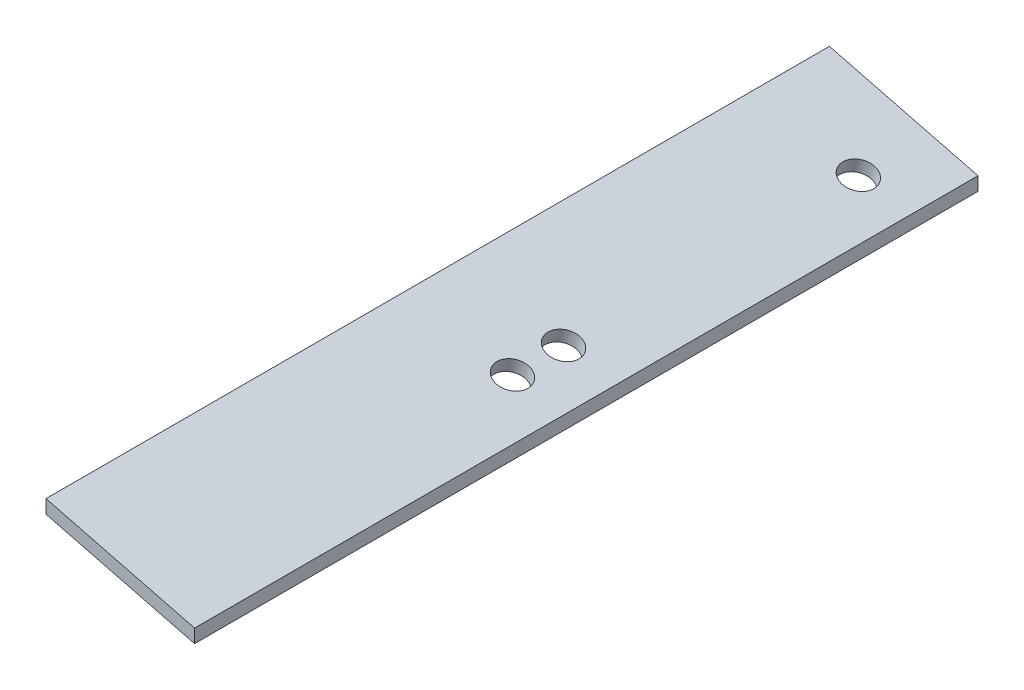
from build123d import *

# Parameters (mm, degrees)
BOSS_EXTRU_1_DEPTH      = 580
ESQUISSE2_R             = 11.8
ENL_V_MAT_EXTRU_1_DEPTH = 10


with BuildPart() as part:
    # Esquisse1 → Boss.-Extru.1 (new body)
    with BuildSketch(Plane.XY):
        Polygon((120, 155), (10, 183), (10, 173), (120, 145), align=None)
    extrude(amount=-BOSS_EXTRU_1_DEPTH)

    # Esquisse2 → Enlèv. mat.-Extru.1 (cut)
    with BuildSketch(Plane(origin=(44.355790127, 174.254889786, 0), x_dir=(0.969097174, -0.246679281, 0), z_dir=(0.246679281, 0.969097174, 0))):
        with Locations((41.344408766, 308.745926628)):
            Circle(ESQUISSE2_R)
        with Locations((41.344408766, 270.946985721)):
            Circle(ESQUISSE2_R)
        with Locations((41.344408766, 527)):
            Circle(ESQUISSE2_R)
    extrude(amount=-ENL_V_MAT_EXTRU_1_DEPTH, mode=Mode.SUBTRACT)


solid = part.part
